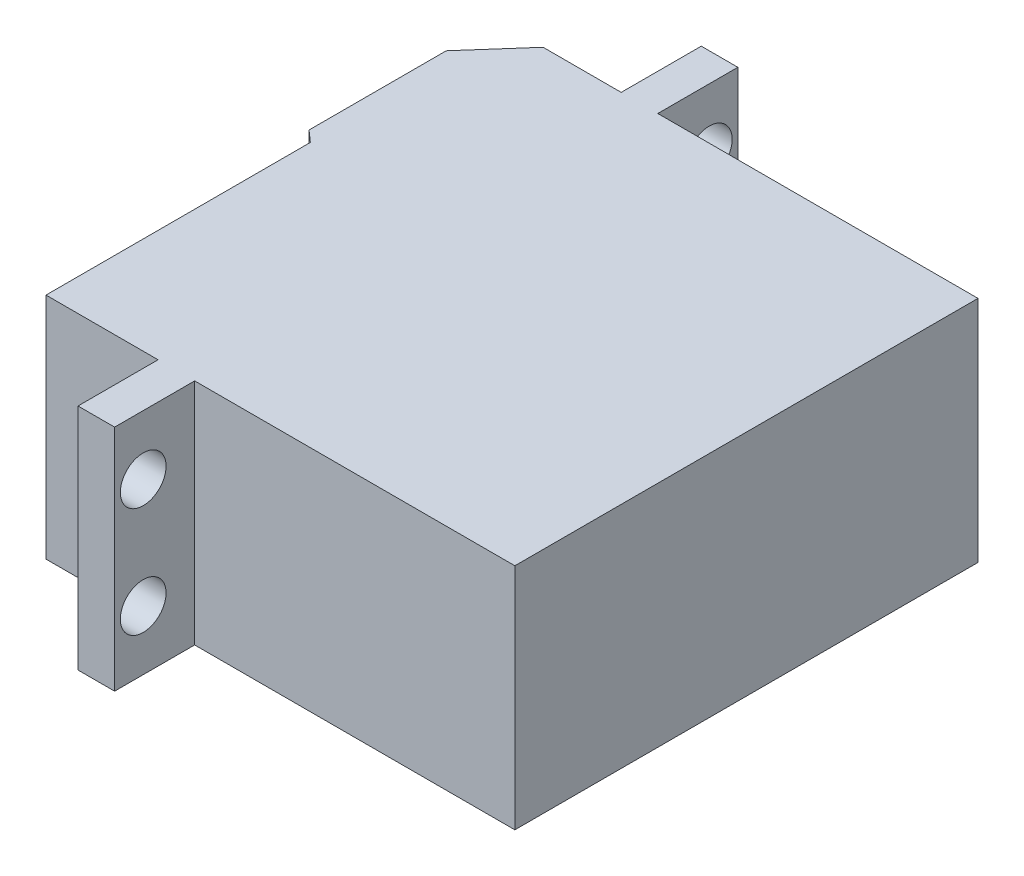
from build123d import *

# Parameters (mm, degrees)
BOSS_EXTRUDE1_DEPTH = 20
BOSS_EXTRUDE2_DEPTH = 4
SKETCH3_R           = 2
CUT_EXTRUDE1_DEPTH  = 32.2
SKETCH4_R           = 1.5
CUT_EXTRUDE2_DEPTH  = 2


with BuildPart() as part:
    # Sketch1 → Boss-Extrude1 (new body)
    with BuildSketch(Plane(origin=(0, 0, 0), x_dir=(1, 0, 0), z_dir=(0, 1, 0))):
        Polygon((0, 0), (0, 40.5), (-28, 40.5), (-28, 47.5), (-31.2, 47.5), (-31.2, 40.5), (-38.031373033, 40.5), (-42, 36), (-42, 24), (-41, 23.118082896), (-41, 0), (-31.2, 0), (-31.2, -7), (-28, -7), (-28, 0), align=None)
    extrude(amount=BOSS_EXTRUDE1_DEPTH)

    # Sketch2 → Boss-Extrude2 (add)
    with BuildSketch(Plane.ZY.offset(42)):
        Polygon((-33.464101615, 10), (-31.732050808, 7), (-28.267949192, 7), (-26.535898385, 10), (-28.267949192, 13), (-31.732050808, 13), align=None)
    extrude(amount=BOSS_EXTRUDE2_DEPTH)

    # Sketch3 → Cut-Extrude1 (cut, through all)
    with BuildSketch(Plane.ZY.offset(31.2)):
        with Locations((-45, 5.2)):
            Circle(SKETCH3_R)
        with Locations((-45, 14.8)):
            Circle(SKETCH3_R)
        with Locations((4.5, 14.8)):
            Circle(SKETCH3_R)
        with Locations((4.5, 5.2)):
            Circle(SKETCH3_R)
    extrude(amount=-CUT_EXTRUDE1_DEPTH, mode=Mode.SUBTRACT)

    # Sketch4 → Cut-Extrude2 (cut)
    with BuildSketch(Plane.ZY.offset(46)):
        with Locations((-30, 10)):
            Circle(SKETCH4_R)
    extrude(amount=-CUT_EXTRUDE2_DEPTH, mode=Mode.SUBTRACT)


solid = part.part
